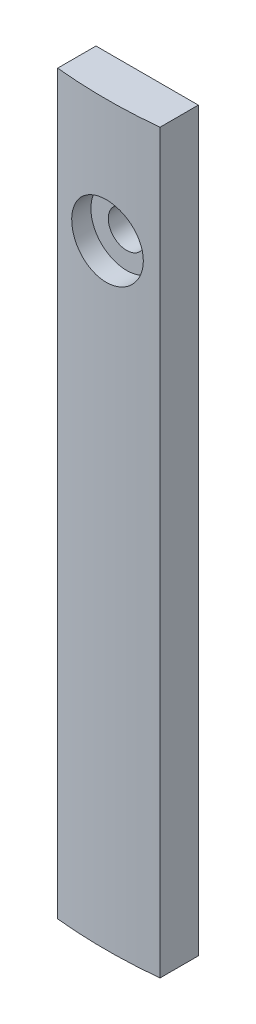
from build123d import *

# Parameters (mm, degrees)
EXTRUDE_1_DEPTH              = 72
HOLE_WIZARD_M3_1_D           = 3.6
HOLE_WIZARD_M3_1_DEPTH       = 4
HOLE_WIZARD_M3_1_CBORE_D     = 7
HOLE_WIZARD_M3_1_CBORE_DEPTH = 2


with BuildPart() as part:
    # 草图1 → 凸台-拉伸1 (new body)
    with BuildSketch(Plane(origin=(0, 72, 0), x_dir=(1, 0, 0), z_dir=(0, 1, 0))):
        with BuildLine():
            Line((1135, -1.494230428), (1135, 2.25))
            Line((1135, 2.25), (1125, 2.25))
            Line((1125, 2.25), (1125, -1.494230428))
            ThreePointArc((1125, -1.494230428), (1130, -1.75), (1135, -1.494230428))
        make_face()
    extrude(amount=-EXTRUDE_1_DEPTH)

    # M3 六角头机械螺钉的柱形沉头孔1
    with Locations(Plane(origin=(1130, 60, 1.75), x_dir=(1, 0, 0), z_dir=(0, 0, 1))):
        with Locations((0, 0)):
            CounterBoreHole(HOLE_WIZARD_M3_1_D / 2, HOLE_WIZARD_M3_1_CBORE_D / 2, HOLE_WIZARD_M3_1_CBORE_DEPTH, depth=HOLE_WIZARD_M3_1_DEPTH)


solid = part.part
